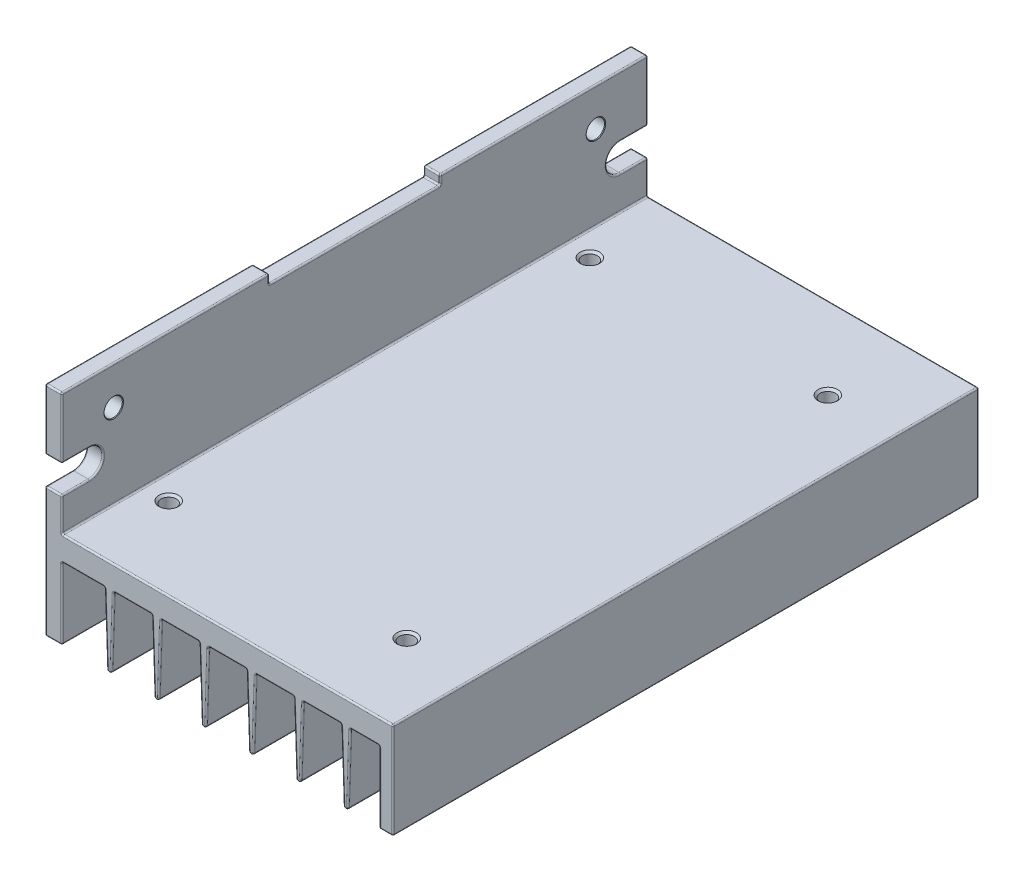
from build123d import *

# Parameters (mm, degrees)
BODY_DEPTH                  = 48
TOP_CUT_OUT_SKETCH_W        = 28
TOP_CUT_OUT_SKETCH_H        = 28
TOP_CUT_OUT_DEPTH           = 1.5
SIDE_CUT_OUT_DEPTH          = 3.75
M3_TOP_HOLES_AT_2_COUNT     = 2
M3_TOP_HOLES_AT_2_PITCH     = 69
M3_TOP_HOLES_AT_3_COUNT     = 2
M3_TOP_HOLES_AT_3_PITCH     = 79.259068882
M3_TOP_HOLES_AT_4_COUNT     = 2
M3_TOP_HOLES_AT_4_PITCH     = 39
F_3_0_SIDE_HOLES_AT_2_COUNT = 2
F_3_0_SIDE_HOLES_AT_2_PITCH = 79
PRODUCTION_FILLET_R         = 0.25


with BuildPart() as part:
    # Body Profile Sketch → Body (new body, symmetric)
    with BuildSketch(Plane.XY):
        with BuildLine():
            Line((0.25, 0), (54, 0))
            ThreePointArc((54, 0), (54.176776695, -0.073223305), (54.25, -0.25))
            Line((54.25, -0.25), (54.25, -15.5))
            ThreePointArc((54.25, -15.5), (54.176776695, -15.676776695), (54, -15.75))
            Line((54, -15.75), (52.25, -15.75))
            ThreePointArc((52.25, -15.75), (52.073223305, -15.676776695), (52, -15.5))
            Line((52, -15.5), (52, -4.25))
            ThreePointArc((52, -4.25), (51.926776695, -4.073223305), (51.75, -4))
            Line((51.75, -4), (47.491898383, -4))
            ThreePointArc((47.491898383, -4), (47.318056795, -4.070336141), (47.242033979, -4.241767182))
            Line((47.242033979, -4.241767182), (46.874796607, -15.387349227))
            ThreePointArc((46.874796607, -15.387349227), (46.5, -15.75), (46.125203393, -15.387349227))
            Line((46.125203393, -15.387349227), (45.757966021, -4.241767182))
            ThreePointArc((45.757966021, -4.241767182), (45.681943205, -4.070336141), (45.508101617, -4))
            Line((45.508101617, -4), (39.741898383, -4))
            ThreePointArc((39.741898383, -4), (39.568056795, -4.070336141), (39.492033979, -4.241767182))
            Line((39.492033979, -4.241767182), (39.124796607, -15.387349227))
            ThreePointArc((39.124796607, -15.387349227), (38.75, -15.75), (38.375203393, -15.387349227))
            Line((38.375203393, -15.387349227), (38.007966021, -4.241767182))
            ThreePointArc((38.007966021, -4.241767182), (37.931943205, -4.070336141), (37.758101617, -4))
            Line((37.758101617, -4), (31.991898383, -4))
            ThreePointArc((31.991898383, -4), (31.818056795, -4.070336141), (31.742033979, -4.241767182))
            Line((31.742033979, -4.241767182), (31.374796607, -15.387349227))
            ThreePointArc((31.374796607, -15.387349227), (31, -15.75), (30.625203393, -15.387349227))
            Line((30.625203393, -15.387349227), (30.257966021, -4.241767182))
            ThreePointArc((30.257966021, -4.241767182), (30.181943205, -4.070336141), (30.008101617, -4))
            Line((30.008101617, -4), (24.241898383, -4))
            ThreePointArc((24.241898383, -4), (24.068056795, -4.070336141), (23.992033979, -4.241767182))
            Line((23.992033979, -4.241767182), (23.624796607, -15.387349227))
            ThreePointArc((23.624796607, -15.387349227), (23.25, -15.75), (22.875203393, -15.387349227))
            Line((22.875203393, -15.387349227), (22.507966021, -4.241767182))
            ThreePointArc((22.507966021, -4.241767182), (22.431943205, -4.070336141), (22.258101617, -4))
            Line((22.258101617, -4), (16.491898383, -4))
            ThreePointArc((16.491898383, -4), (16.318056795, -4.070336141), (16.242033979, -4.241767182))
            Line((16.242033979, -4.241767182), (15.874796607, -15.387349227))
            ThreePointArc((15.874796607, -15.387349227), (15.5, -15.75), (15.125203393, -15.387349227))
            Line((15.125203393, -15.387349227), (14.757966021, -4.241767182))
            ThreePointArc((14.757966021, -4.241767182), (14.681943205, -4.070336141), (14.508101617, -4))
            Line((14.508101617, -4), (8.741898383, -4))
            ThreePointArc((8.741898383, -4), (8.568056795, -4.070336141), (8.492033979, -4.241767182))
            Line((8.492033979, -4.241767182), (8.124796607, -15.387349227))
            ThreePointArc((8.124796607, -15.387349227), (7.75, -15.75), (7.375203393, -15.387349227))
            Line((7.375203393, -15.387349227), (7.007966021, -4.241767182))
            ThreePointArc((7.007966021, -4.241767182), (6.931943205, -4.070336141), (6.758101617, -4))
            Line((6.758101617, -4), (0.25, -4))
            ThreePointArc((0.25, -4), (0.073223305, -4.073223305), (0, -4.25))
            Line((0, -4.25), (0, -15.5))
            ThreePointArc((0, -15.5), (-0.073223305, -15.676776695), (-0.25, -15.75))
            Line((-0.25, -15.75), (-2.5, -15.75))
            ThreePointArc((-2.5, -15.75), (-2.676776695, -15.676776695), (-2.75, -15.5))
            Line((-2.75, -15.5), (-2.75, 19.75))
            ThreePointArc((-2.75, 19.75), (-2.676776695, 19.926776695), (-2.5, 20))
            Line((-2.5, 20), (-0.25, 20))
            ThreePointArc((-0.25, 20), (-0.073223305, 19.926776695), (0, 19.75))
            Line((0, 19.75), (0, 0.25))
            ThreePointArc((0, 0.25), (0.073223305, 0.073223305), (0.25, 0))
        make_face()
    extrude(amount=BODY_DEPTH, both=True)

    # Top Cut Out Sketch → Top Cut Out (cut)
    with BuildSketch(Plane(origin=(0, 20, 0), x_dir=(1, 0, 0), z_dir=(0, 1, 0))):
        Rectangle(TOP_CUT_OUT_SKETCH_W, TOP_CUT_OUT_SKETCH_H)
    extrude(amount=-TOP_CUT_OUT_DEPTH, mode=Mode.SUBTRACT)

    # Side Cut Out Sketch → Side Cut Out (cut, through all)
    with BuildSketch(Plane(origin=(0, 0, 0), x_dir=(0, 0, -1), z_dir=(1, 0, 0))):
        with BuildLine():
            Line((48, 10), (43.5, 10))
            ThreePointArc((43.5, 10), (41.25, 7.75), (43.5, 5.5))
            Line((43.5, 5.5), (48, 5.5))
            Line((48, 5.5), (48, 10))
        make_face()
        with BuildLine():
            Line((-48, 10), (-43.5, 10))
            ThreePointArc((-43.5, 10), (-41.25, 7.75), (-43.5, 5.5))
            Line((-43.5, 5.5), (-48, 5.5))
            Line((-48, 5.5), (-48, 10))
        make_face()
    extrude(amount=-SIDE_CUT_OUT_DEPTH, mode=Mode.SUBTRACT)

    # Sketch4 → M3 Top Holes (revolve, cut)
    with BuildSketch(Plane(origin=(43, 0, -34.5), x_dir=(0, 0, 1), z_dir=(1, 0, 0))):
        Polygon((0, 0), (0, 4), (1.6, 4), (1.25, 3.65), (1.25, 0.35), (1.6, 0), align=None)
    m3_top_holes = revolve(axis=Axis((43, 6.35, -34.5), (0, -1, 0)), mode=Mode.SUBTRACT)

    # M3 Top Holes at 2: M3 Top Holes ×2
    with Locations(*[(0, 0, i * M3_TOP_HOLES_AT_2_PITCH) for i in range(1, M3_TOP_HOLES_AT_2_COUNT)]):
        add(m3_top_holes, mode=Mode.SUBTRACT)

    # M3 Top Holes at 3: M3 Top Holes ×2
    with Locations(*[Vector(-0.492057257, 0, 0.870562839) * (i * M3_TOP_HOLES_AT_3_PITCH) for i in range(1, M3_TOP_HOLES_AT_3_COUNT)]):
        add(m3_top_holes, mode=Mode.SUBTRACT)

    # M3 Top Holes at 4: M3 Top Holes ×2
    with Locations(*[(-i * M3_TOP_HOLES_AT_4_PITCH, 0, 0) for i in range(1, M3_TOP_HOLES_AT_4_COUNT)]):
        add(m3_top_holes, mode=Mode.SUBTRACT)

    # Sketch6 → Ø3.0 Side Holes (revolve, cut)
    with BuildSketch(Plane(origin=(0, 13.75, -39.5), x_dir=(0, 0, -1), z_dir=(0, 1, 0))):
        Polygon((0, 0), (0, 2.75), (1.6, 2.75), (1.5, 2.65), (1.5, 0.1), (1.6, 0), align=None)
    f_3_0_side_holes = revolve(axis=Axis((6.35, 13.75, -39.5), (-1, 0, 0)), mode=Mode.SUBTRACT)

    # Ø3.0 Side Holes at 2: Ø3.0 Side Holes ×2
    with Locations(*[(0, 0, i * F_3_0_SIDE_HOLES_AT_2_PITCH) for i in range(1, F_3_0_SIDE_HOLES_AT_2_COUNT)]):
        add(f_3_0_side_holes, mode=Mode.SUBTRACT)

    # Production Fillet
    production_fillet_edges = [part.edges().sort_by_distance(p)[0] for p in [
        (-1.375, 20, -14),
        (-0.073223305, 19.926776695, -14),
        (-0.073223305, 19.926776695, 14),
        (-2.676776695, 19.926776695, 14),
        (0, 19.125, -14),
        (-2.75, 19.125, -14),
        (-2.75, 19.125, 14),
        (-2.75, 10, -45.75),
        (-2.75, 7.75, -41.25),
        (0, 10, -45.75),
        (0, 7.75, -41.25),
        (-2.75, 10, 45.75),
        (0, 7.75, 41.25),
        (0, 2.875, 48),
        (0.073223305, 0.073223305, 48),
        (27.125, 0, 48),
        (54.176776695, -0.073223305, 48),
        (54.25, -7.875, 48),
        (54.176776695, -15.676776695, 48),
        (53.125, -15.75, 48),
        (52.073223305, -15.676776695, 48),
        (52, -9.875, 48),
        (51.926776695, -4.073223305, 48),
        (49.620949192, -4, 48),
        (47.318056795, -4.070336141, 48),
        (47.058415293, -9.814558204, 48),
        (46.5, -15.75, 48),
        (45.941584707, -9.814558204, 48),
        (42.625, -4, 48),
        (39.568056795, -4.070336141, 48),
        (39.308415293, -9.814558204, 48),
        (38.75, -15.75, 48),
        (37.931943205, -4.070336141, 48),
        (34.875, -4, 48),
        (31.818056795, -4.070336141, 48),
        (31.558415293, -9.814558204, 48),
        (31, -15.75, 48),
        (30.441584707, -9.814558204, 48),
        (30.181943205, -4.070336141, 48),
        (27.125, -4, 48),
        (24.068056795, -4.070336141, 48),
        (23.808415293, -9.814558204, 48),
        (23.25, -15.75, 48),
        (22.691584707, -9.814558204, 48),
        (22.431943205, -4.070336141, 48),
        (19.375, -4, 48),
        (16.318056795, -4.070336141, 48),
        (16.058415293, -9.814558204, 48),
        (15.5, -15.75, 48),
        (14.941584707, -9.814558204, 48),
        (14.681943205, -4.070336141, 48),
        (11.625, -4, 48),
        (8.308415293, -9.814558204, 48),
        (7.75, -15.75, 48),
        (7.191584707, -9.814558204, 48),
        (6.931943205, -4.070336141, 48),
        (0.073223305, -4.073223305, 48),
        (0, -9.875, 48),
        (-0.073223305, -15.676776695, 48),
        (-1.375, -15.75, 48),
        (-2.75, -5, -48),
        (-2.676776695, -15.676776695, -48),
        (-1.375, -15.75, -48),
        (0, -9.875, -48),
        (0.073223305, -4.073223305, -48),
        (3.504050808, -4, -48),
        (7.191584707, -9.814558204, -48),
        (8.568056795, -4.070336141, -48),
        (11.625, -4, -48),
        (14.681943205, -4.070336141, -48),
        (14.941584707, -9.814558204, -48),
        (15.5, -15.75, -48),
        (16.058415293, -9.814558204, -48),
        (16.318056795, -4.070336141, -48),
        (19.375, -4, -48),
        (22.431943205, -4.070336141, -48),
        (22.691584707, -9.814558204, -48),
        (23.25, -15.75, -48),
        (23.808415293, -9.814558204, -48),
        (24.068056795, -4.070336141, -48),
        (27.125, -4, -48),
        (31.818056795, -4.070336141, -48),
        (34.875, -4, -48),
        (38.191584707, -9.814558204, -48),
        (38.75, -15.75, -48),
        (39.308415293, -9.814558204, -48),
        (39.568056795, -4.070336141, -48),
        (42.625, -4, -48),
        (45.681943205, -4.070336141, -48),
        (45.941584707, -9.814558204, -48),
        (46.5, -15.75, -48),
        (47.058415293, -9.814558204, -48),
        (47.318056795, -4.070336141, -48),
        (49.620949192, -4, -48),
        (51.926776695, -4.073223305, -48),
        (52, -9.875, -48),
        (52.073223305, -15.676776695, -48),
        (53.125, -15.75, -48),
        (54.25, -7.875, -48),
        (54.176776695, -0.073223305, -48),
        (27.125, 0, -48),
        (0.073223305, 0.073223305, -48),
        (0, 2.875, -48),
        (-2.75, 5.5, -45.75),
        (-1.375, 5.5, -48),
        (0, 5.5, -45.75),
        (-0.073223305, 19.926776695, -48),
        (-1.375, 20, -48),
        (-2.676776695, 19.926776695, -48),
        (-2.75, 14.875, -48),
        (-1.375, 10, -48),
        (-1.375, 5.5, 48),
        (0, 5.5, 45.75),
        (-2.676776695, 19.926776695, 48),
        (-1.375, 20, 48),
        (-0.073223305, 19.926776695, 48),
        (0, 14.875, 48),
        (-1.375, 10, 48),
        (-2.75, 14.875, 48),
        (-1.375, 18.5, -14),
        (0, 18.5, 0),
        (-1.375, 18.5, 14),
        (-2.75, 18.5, 0),
        (-2.75, -5, 48),
    ]]
    fillet(production_fillet_edges, radius=PRODUCTION_FILLET_R)


solid = part.part
